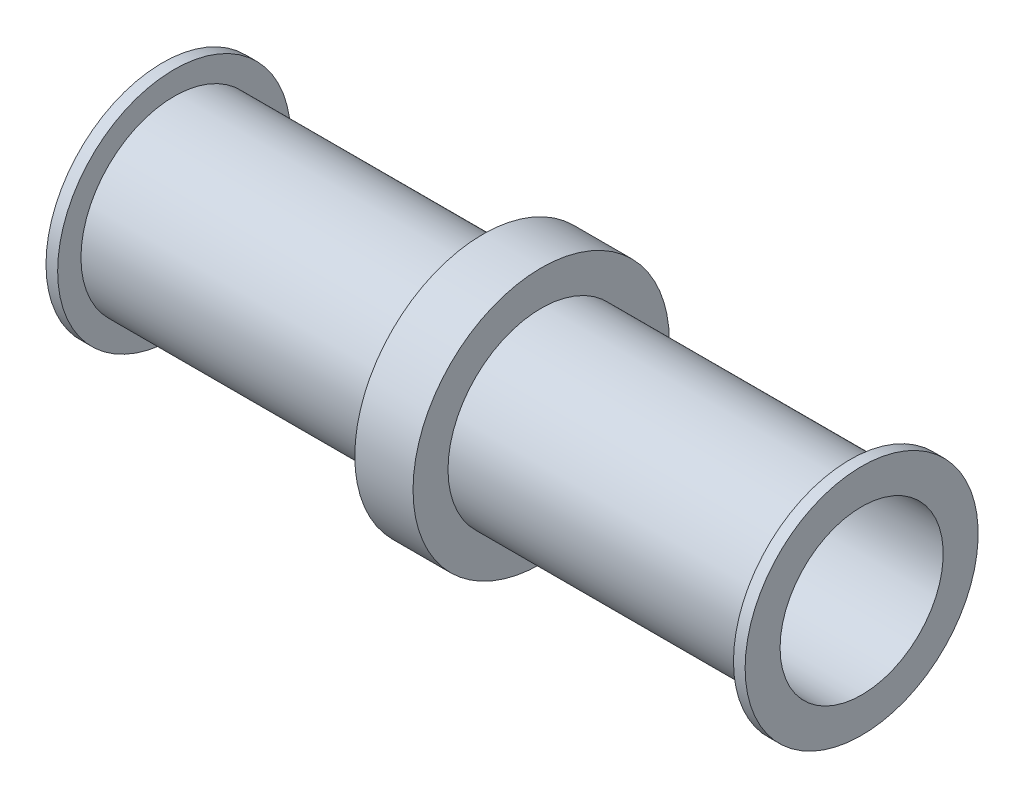
from build123d import *


with BuildPart() as part:
    # Sketch1 → Revolve1 (revolve)
    with BuildSketch(Plane.XY):
        Polygon((0, 1.778), (0, 2.54), (0.254, 2.54), (0.254, 2.032), (6.985, 2.032), (6.985, 2.794), (8.255, 2.794), (8.255, 2.032), (14.986, 2.032), (14.986, 2.54), (15.24, 2.54), (15.24, 1.778), align=None)
    revolve(axis=Axis((0, 0, 0), (1, 0, 0)))


solid = part.part
